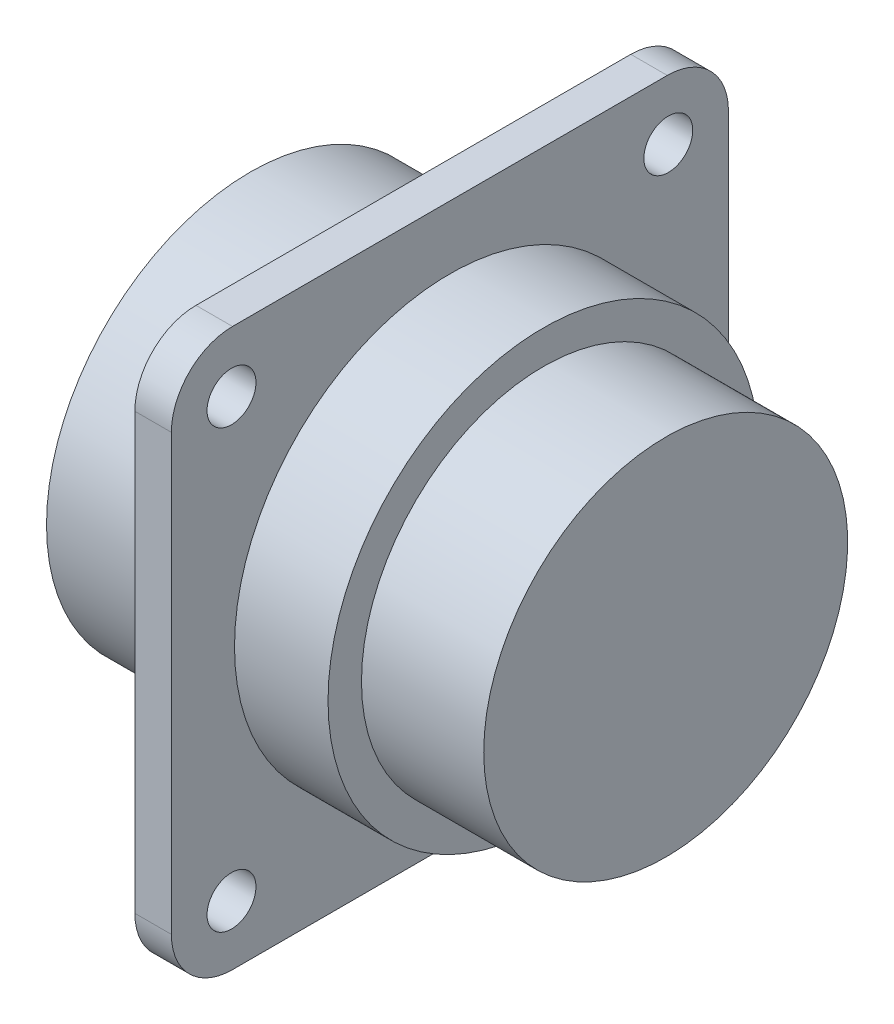
from build123d import *

# Parameters (mm, degrees)
SKETCH2_OUTSIDE_W  = 79.82
SKETCH2_OUTSIDE_H  = 79.82
SKETCH2_OUTSIDE_R  = 1.6
CUT_EXTRUDE1_DEPTH = 10
SKETCH3_R          = 12
CUT_EXTRUDE2_DEPTH = 10


with BuildPart() as part:
    # Sketch1 → Revolve1 (revolve)
    with BuildSketch(Plane.XY, mode=Mode.PRIVATE) as revolve1_sk:
        Polygon((0, 0), (0, 13.335), (10.67, 13.335), (10.67, 30), (13.06, 30), (13.06, 14.095), (19.18, 14.095), (19.18, 11.90625), (27.18, 11.90625), (27.18, 0), align=None)
    revolve(revolve1_sk.sketch.rotate(Axis((0, 0, 0), (1, 0, 0)), 90), axis=Axis((0, 0, 0), (1, 0, 0)))  # turned: the seam where the file's is

    # Sketch2 outside → Cut-Extrude1 (cut)
    with BuildSketch(Plane.ZY.offset(-10.67)):
        Rectangle(SKETCH2_OUTSIDE_W, SKETCH2_OUTSIDE_H)
        with BuildLine():
            Line((-14.225, 18.225), (14.225, 18.225))
            ThreePointArc((14.225, 18.225), (17.053427125, 17.053427125), (18.225, 14.225))
            Line((18.225, 14.225), (18.225, -14.225))
            ThreePointArc((18.225, -14.225), (17.053427125, -17.053427125), (14.225, -18.225))
            Line((14.225, -18.225), (-14.225, -18.225))
            ThreePointArc((-14.225, -18.225), (-17.053427125, -17.053427125), (-18.225, -14.225))
            Line((-18.225, -14.225), (-18.225, 14.225))
            ThreePointArc((-18.225, 14.225), (-17.053427125, 17.053427125), (-14.225, 18.225))
        make_face(mode=Mode.SUBTRACT)
        with Locations((-14.29, 14.29)):
            Circle(SKETCH2_OUTSIDE_R)
        with Locations((14.29, 14.29)):
            Circle(SKETCH2_OUTSIDE_R)
        with Locations((14.29, -14.29)):
            Circle(SKETCH2_OUTSIDE_R)
        with Locations((-14.29, -14.29)):
            Circle(SKETCH2_OUTSIDE_R)
    extrude(amount=-CUT_EXTRUDE1_DEPTH, mode=Mode.SUBTRACT)

    # Sketch3 → Cut-Extrude2 (cut)
    with BuildSketch(Plane.ZY):
        Circle(SKETCH3_R)
    extrude(amount=-CUT_EXTRUDE2_DEPTH, mode=Mode.SUBTRACT)


solid = part.part
